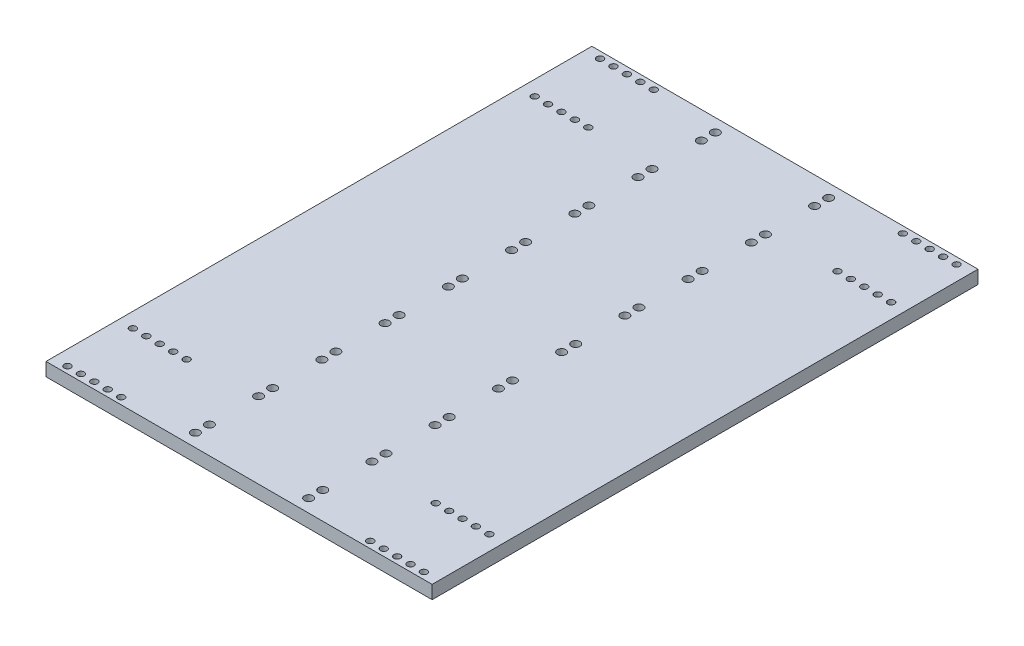
from build123d import *

# Parameters (mm, degrees)
SKETCH1_W           = 184.15
SKETCH1_H           = 260.35
BOSS_EXTRUDE1_DEPTH = 6.35
SKETCH2_R           = 2.032
CUT_EXTRUDE1_DEPTH  = 7.35
SKETCH3_R           = 1.6
CUT_EXTRUDE2_DEPTH  = 6.35


with BuildPart() as part:
    # Sketch1 → Boss-Extrude1 (new body)
    with BuildSketch(Plane(origin=(0, 0, 0), x_dir=(1, 0, 0), z_dir=(0, 1, 0))):
        Rectangle(SKETCH1_W, SKETCH1_H)
    extrude(amount=-BOSS_EXTRUDE1_DEPTH)

    # Sketch2 → Cut-Extrude1 (cut, through all)
    with BuildSketch(Plane(origin=(0, 0, 0), x_dir=(1, 0, 0), z_dir=(0, 1, 0))):
        with BuildLine():
            ThreePointArc((-24.98852, 117.2972), (-25.583679021, 118.734040979), (-27.02052, 119.3292))
            Line((-27.02052, 119.3292), (-27.02052, 117.2972))
            Line((-27.02052, 117.2972), (-24.98852, 117.2972))
        make_face()
        with BuildLine():
            Line((-27.02052, 117.2972), (-27.02052, 119.3292))
            ThreePointArc((-27.02052, 119.3292), (-28.457360979, 115.860359021), (-24.98852, 117.2972))
            Line((-24.98852, 117.2972), (-27.02052, 117.2972))
        make_face()
        with BuildLine():
            ThreePointArc((29.05252, 124.0028), (27.02052, 126.0348), (24.98852, 124.0028))
            Line((24.98852, 124.0028), (27.02052, 124.0028))
            Line((27.02052, 124.0028), (27.02052, 121.9708))
            ThreePointArc((27.02052, 121.9708), (28.457360979, 122.565959021), (29.05252, 124.0028))
        make_face()
        with BuildLine():
            Line((27.02052, 124.0028), (24.98852, 124.0028))
            ThreePointArc((24.98852, 124.0028), (25.583679021, 122.565959021), (27.02052, 121.9708))
            Line((27.02052, 121.9708), (27.02052, 124.0028))
        make_face()
        with BuildLine():
            ThreePointArc((27.02052, 119.3292), (25.583679021, 118.734040979), (24.98852, 117.2972))
            Line((24.98852, 117.2972), (27.02052, 117.2972))
            Line((27.02052, 117.2972), (27.02052, 119.3292))
        make_face()
        with BuildLine():
            Line((27.02052, 117.2972), (24.98852, 117.2972))
            ThreePointArc((24.98852, 117.2972), (27.02052, 115.2652), (29.05252, 117.2972))
            ThreePointArc((29.05252, 117.2972), (28.457360979, 118.734040979), (27.02052, 119.3292))
            Line((27.02052, 119.3292), (27.02052, 117.2972))
        make_face()
        with BuildLine():
            Line((-24.98852, 93.8403), (-27.02052, 93.8403))
            Line((-27.02052, 93.8403), (-27.02052, 91.8083))
            ThreePointArc((-27.02052, 91.8083), (-25.583679021, 92.403459021), (-24.98852, 93.8403))
        make_face()
        with BuildLine():
            Line((-27.02052, 91.8083), (-27.02052, 93.8403))
            Line((-27.02052, 93.8403), (-24.98852, 93.8403))
            ThreePointArc((-24.98852, 93.8403), (-28.457360979, 95.277140979), (-27.02052, 91.8083))
        make_face()
        with BuildLine():
            ThreePointArc((-24.98852, 87.1347), (-25.583679021, 88.571540979), (-27.02052, 89.1667))
            Line((-27.02052, 89.1667), (-27.02052, 87.1347))
            Line((-27.02052, 87.1347), (-24.98852, 87.1347))
        make_face()
        with BuildLine():
            Line((-27.02052, 87.1347), (-27.02052, 89.1667))
            ThreePointArc((-27.02052, 89.1667), (-28.457360979, 85.697859021), (-24.98852, 87.1347))
            Line((-24.98852, 87.1347), (-27.02052, 87.1347))
        make_face()
        with BuildLine():
            ThreePointArc((29.05252, 93.8403), (27.02052, 95.8723), (24.98852, 93.8403))
            Line((24.98852, 93.8403), (27.02052, 93.8403))
            Line((27.02052, 93.8403), (27.02052, 91.8083))
            ThreePointArc((27.02052, 91.8083), (28.457360979, 92.403459021), (29.05252, 93.8403))
        make_face()
        with BuildLine():
            Line((27.02052, 93.8403), (24.98852, 93.8403))
            ThreePointArc((24.98852, 93.8403), (25.583679021, 92.403459021), (27.02052, 91.8083))
            Line((27.02052, 91.8083), (27.02052, 93.8403))
        make_face()
        with BuildLine():
            ThreePointArc((27.02052, 89.1667), (25.583679021, 88.571540979), (24.98852, 87.1347))
            Line((24.98852, 87.1347), (27.02052, 87.1347))
            Line((27.02052, 87.1347), (27.02052, 89.1667))
        make_face()
        with BuildLine():
            Line((27.02052, 87.1347), (24.98852, 87.1347))
            ThreePointArc((24.98852, 87.1347), (27.02052, 85.1027), (29.05252, 87.1347))
            ThreePointArc((29.05252, 87.1347), (28.457360979, 88.571540979), (27.02052, 89.1667))
            Line((27.02052, 89.1667), (27.02052, 87.1347))
        make_face()
        with BuildLine():
            Line((-24.98852, 124.0028), (-27.02052, 124.0028))
            Line((-27.02052, 124.0028), (-27.02052, 121.9708))
            ThreePointArc((-27.02052, 121.9708), (-25.583679021, 122.565959021), (-24.98852, 124.0028))
        make_face()
        with BuildLine():
            Line((-27.02052, 121.9708), (-27.02052, 124.0028))
            Line((-27.02052, 124.0028), (-24.98852, 124.0028))
            ThreePointArc((-24.98852, 124.0028), (-28.457360979, 125.439640979), (-27.02052, 121.9708))
        make_face()
        with BuildLine():
            Line((-24.98852, 63.6778), (-27.02052, 63.6778))
            Line((-27.02052, 63.6778), (-27.02052, 61.6458))
            ThreePointArc((-27.02052, 61.6458), (-25.583679021, 62.240959021), (-24.98852, 63.6778))
        make_face()
        with BuildLine():
            Line((-27.02052, 61.6458), (-27.02052, 63.6778))
            Line((-27.02052, 63.6778), (-24.98852, 63.6778))
            ThreePointArc((-24.98852, 63.6778), (-28.457360979, 65.114640979), (-27.02052, 61.6458))
        make_face()
        with BuildLine():
            ThreePointArc((-24.98852, 56.9722), (-25.583679021, 58.409040979), (-27.02052, 59.0042))
            Line((-27.02052, 59.0042), (-27.02052, 56.9722))
            Line((-27.02052, 56.9722), (-24.98852, 56.9722))
        make_face()
        with BuildLine():
            Line((-27.02052, 56.9722), (-27.02052, 59.0042))
            ThreePointArc((-27.02052, 59.0042), (-28.457360979, 55.535359021), (-24.98852, 56.9722))
            Line((-24.98852, 56.9722), (-27.02052, 56.9722))
        make_face()
        with BuildLine():
            ThreePointArc((29.05252, 63.6778), (27.02052, 65.7098), (24.98852, 63.6778))
            Line((24.98852, 63.6778), (27.02052, 63.6778))
            Line((27.02052, 63.6778), (27.02052, 61.6458))
            ThreePointArc((27.02052, 61.6458), (28.457360979, 62.240959021), (29.05252, 63.6778))
        make_face()
        with BuildLine():
            Line((27.02052, 63.6778), (24.98852, 63.6778))
            ThreePointArc((24.98852, 63.6778), (25.583679021, 62.240959021), (27.02052, 61.6458))
            Line((27.02052, 61.6458), (27.02052, 63.6778))
        make_face()
        with BuildLine():
            ThreePointArc((27.02052, 59.0042), (25.583679021, 58.409040979), (24.98852, 56.9722))
            Line((24.98852, 56.9722), (27.02052, 56.9722))
            Line((27.02052, 56.9722), (27.02052, 59.0042))
        make_face()
        with BuildLine():
            Line((27.02052, 56.9722), (24.98852, 56.9722))
            ThreePointArc((24.98852, 56.9722), (27.02052, 54.9402), (29.05252, 56.9722))
            ThreePointArc((29.05252, 56.9722), (28.457360979, 58.409040979), (27.02052, 59.0042))
            Line((27.02052, 59.0042), (27.02052, 56.9722))
        make_face()
        with BuildLine():
            Line((-24.98852, 33.5153), (-27.02052, 33.5153))
            Line((-27.02052, 33.5153), (-27.02052, 31.4833))
            ThreePointArc((-27.02052, 31.4833), (-25.583679021, 32.078459021), (-24.98852, 33.5153))
        make_face()
        with BuildLine():
            Line((-27.02052, 31.4833), (-27.02052, 33.5153))
            Line((-27.02052, 33.5153), (-24.98852, 33.5153))
            ThreePointArc((-24.98852, 33.5153), (-28.457360979, 34.952140979), (-27.02052, 31.4833))
        make_face()
        with BuildLine():
            ThreePointArc((-24.98852, 26.8097), (-25.583679021, 28.246540979), (-27.02052, 28.8417))
            Line((-27.02052, 28.8417), (-27.02052, 26.8097))
            Line((-27.02052, 26.8097), (-24.98852, 26.8097))
        make_face()
        with BuildLine():
            Line((-27.02052, 26.8097), (-27.02052, 28.8417))
            ThreePointArc((-27.02052, 28.8417), (-28.457360979, 25.372859021), (-24.98852, 26.8097))
            Line((-24.98852, 26.8097), (-27.02052, 26.8097))
        make_face()
        with BuildLine():
            ThreePointArc((29.05252, 33.5153), (27.02052, 35.5473), (24.98852, 33.5153))
            Line((24.98852, 33.5153), (27.02052, 33.5153))
            Line((27.02052, 33.5153), (27.02052, 31.4833))
            ThreePointArc((27.02052, 31.4833), (28.457360979, 32.078459021), (29.05252, 33.5153))
        make_face()
        with BuildLine():
            Line((27.02052, 33.5153), (24.98852, 33.5153))
            ThreePointArc((24.98852, 33.5153), (25.583679021, 32.078459021), (27.02052, 31.4833))
            Line((27.02052, 31.4833), (27.02052, 33.5153))
        make_face()
        with BuildLine():
            ThreePointArc((27.02052, 28.8417), (25.583679021, 28.246540979), (24.98852, 26.8097))
            Line((24.98852, 26.8097), (27.02052, 26.8097))
            Line((27.02052, 26.8097), (27.02052, 28.8417))
        make_face()
        with BuildLine():
            Line((27.02052, 26.8097), (24.98852, 26.8097))
            ThreePointArc((24.98852, 26.8097), (27.02052, 24.7777), (29.05252, 26.8097))
            ThreePointArc((29.05252, 26.8097), (28.457360979, 28.246540979), (27.02052, 28.8417))
            Line((27.02052, 28.8417), (27.02052, 26.8097))
        make_face()
        with BuildLine():
            Line((-24.98852, 3.3528), (-27.02052, 3.3528))
            Line((-27.02052, 3.3528), (-27.02052, 1.3208))
            ThreePointArc((-27.02052, 1.3208), (-25.583679021, 1.915959021), (-24.98852, 3.3528))
        make_face()
        with BuildLine():
            Line((-27.02052, 1.3208), (-27.02052, 3.3528))
            Line((-27.02052, 3.3528), (-24.98852, 3.3528))
            ThreePointArc((-24.98852, 3.3528), (-28.457360979, 4.789640979), (-27.02052, 1.3208))
        make_face()
        with BuildLine():
            ThreePointArc((-24.98852, -3.3528), (-25.583679021, -1.915959021), (-27.02052, -1.3208))
            Line((-27.02052, -1.3208), (-27.02052, -3.3528))
            Line((-27.02052, -3.3528), (-24.98852, -3.3528))
        make_face()
        with BuildLine():
            Line((-27.02052, -3.3528), (-27.02052, -1.3208))
            ThreePointArc((-27.02052, -1.3208), (-28.457360979, -4.789640979), (-24.98852, -3.3528))
            Line((-24.98852, -3.3528), (-27.02052, -3.3528))
        make_face()
        with BuildLine():
            ThreePointArc((29.05252, 3.3528), (27.02052, 5.3848), (24.98852, 3.3528))
            Line((24.98852, 3.3528), (27.02052, 3.3528))
            Line((27.02052, 3.3528), (27.02052, 1.3208))
            ThreePointArc((27.02052, 1.3208), (28.457360979, 1.915959021), (29.05252, 3.3528))
        make_face()
        with BuildLine():
            Line((27.02052, 3.3528), (24.98852, 3.3528))
            ThreePointArc((24.98852, 3.3528), (25.583679021, 1.915959021), (27.02052, 1.3208))
            Line((27.02052, 1.3208), (27.02052, 3.3528))
        make_face()
        with BuildLine():
            ThreePointArc((27.02052, -1.3208), (25.583679021, -1.915959021), (24.98852, -3.3528))
            Line((24.98852, -3.3528), (27.02052, -3.3528))
            Line((27.02052, -3.3528), (27.02052, -1.3208))
        make_face()
        with BuildLine():
            Line((27.02052, -3.3528), (24.98852, -3.3528))
            ThreePointArc((24.98852, -3.3528), (27.02052, -5.3848), (29.05252, -3.3528))
            ThreePointArc((29.05252, -3.3528), (28.457360979, -1.915959021), (27.02052, -1.3208))
            Line((27.02052, -1.3208), (27.02052, -3.3528))
        make_face()
        with BuildLine():
            Line((-24.98852, -26.8097), (-27.02052, -26.8097))
            Line((-27.02052, -26.8097), (-27.02052, -28.8417))
            ThreePointArc((-27.02052, -28.8417), (-25.583679021, -28.246540979), (-24.98852, -26.8097))
        make_face()
        with BuildLine():
            Line((-27.02052, -28.8417), (-27.02052, -26.8097))
            Line((-27.02052, -26.8097), (-24.98852, -26.8097))
            ThreePointArc((-24.98852, -26.8097), (-28.457360979, -25.372859021), (-27.02052, -28.8417))
        make_face()
        with Locations((-27.02052, -33.5153)):
            Circle(SKETCH2_R)
        with Locations((27.02052, -26.8097)):
            Circle(SKETCH2_R)
        with Locations((27.02052, -33.5153)):
            Circle(SKETCH2_R)
        with Locations((-27.02052, -56.9722)):
            Circle(SKETCH2_R)
        with Locations((-27.02052, -63.6778)):
            Circle(SKETCH2_R)
        with Locations((27.02052, -56.9722)):
            Circle(SKETCH2_R)
        with Locations((27.02052, -63.6778)):
            Circle(SKETCH2_R)
        with Locations((-27.02052, -87.1347)):
            Circle(SKETCH2_R)
        with Locations((-27.02052, -93.8403)):
            Circle(SKETCH2_R)
        with Locations((27.02052, -87.1347)):
            Circle(SKETCH2_R)
        with Locations((27.02052, -93.8403)):
            Circle(SKETCH2_R)
        with Locations((27.02052, -117.2972)):
            Circle(SKETCH2_R)
        with Locations((-27.02052, -117.2972)):
            Circle(SKETCH2_R)
        with Locations((-27.02052, -124.0028)):
            Circle(SKETCH2_R)
        with Locations((27.02052, -124.0028)):
            Circle(SKETCH2_R)
    extrude(amount=-CUT_EXTRUDE1_DEPTH, mode=Mode.SUBTRACT)

    # Sketch3 → Cut-Extrude2 (cut)
    with BuildSketch(Plane(origin=(0, 0, 0), x_dir=(1, 0, 0), z_dir=(0, 1, 0))):
        with Locations((-59.40552, -95.8)):
            Circle(SKETCH3_R)
        with Locations((-65.80552, -95.8)):
            Circle(SKETCH3_R)
        with Locations((-72.20552, -95.8)):
            Circle(SKETCH3_R)
        with Locations((-78.60552, -95.8)):
            Circle(SKETCH3_R)
        with Locations((-85.00552, -95.8)):
            Circle(SKETCH3_R)
        with Locations((-59.40552, -127)):
            Circle(SKETCH3_R)
        with Locations((-65.80552, -127)):
            Circle(SKETCH3_R)
        with Locations((-72.20552, -127)):
            Circle(SKETCH3_R)
        with Locations((-78.60552, -127)):
            Circle(SKETCH3_R)
        with Locations((-85.00552, -127)):
            Circle(SKETCH3_R)
        with Locations((59.40552, -127)):
            Circle(SKETCH3_R)
        with Locations((59.40552, -95.8)):
            Circle(SKETCH3_R)
        with Locations((65.80552, -95.8)):
            Circle(SKETCH3_R)
        with Locations((72.20552, -95.8)):
            Circle(SKETCH3_R)
        with Locations((78.60552, -95.8)):
            Circle(SKETCH3_R)
        with Locations((85.00552, -95.8)):
            Circle(SKETCH3_R)
        with Locations((65.80552, -127)):
            Circle(SKETCH3_R)
        with Locations((72.20552, -127)):
            Circle(SKETCH3_R)
        with Locations((78.60552, -127)):
            Circle(SKETCH3_R)
        with Locations((85.00552, -127)):
            Circle(SKETCH3_R)
        with Locations((85.00552, 95.8)):
            Circle(SKETCH3_R)
        with Locations((78.60552, 95.8)):
            Circle(SKETCH3_R)
        with Locations((72.20552, 95.8)):
            Circle(SKETCH3_R)
        with Locations((65.80552, 95.8)):
            Circle(SKETCH3_R)
        with Locations((59.40552, 127)):
            Circle(SKETCH3_R)
        with Locations((65.80552, 127)):
            Circle(SKETCH3_R)
        with Locations((72.20552, 127)):
            Circle(SKETCH3_R)
        with Locations((78.60552, 127)):
            Circle(SKETCH3_R)
        with Locations((85.00552, 127)):
            Circle(SKETCH3_R)
        with Locations((59.40552, 95.8)):
            Circle(SKETCH3_R)
        with Locations((-59.40552, 95.8)):
            Circle(SKETCH3_R)
        with Locations((-65.80552, 95.8)):
            Circle(SKETCH3_R)
        with Locations((-72.20552, 95.8)):
            Circle(SKETCH3_R)
        with Locations((-78.60552, 95.8)):
            Circle(SKETCH3_R)
        with Locations((-85.00552, 95.8)):
            Circle(SKETCH3_R)
        with Locations((-59.40552, 127)):
            Circle(SKETCH3_R)
        with Locations((-65.80552, 127)):
            Circle(SKETCH3_R)
        with Locations((-72.20552, 127)):
            Circle(SKETCH3_R)
        with Locations((-78.60552, 127)):
            Circle(SKETCH3_R)
        with Locations((-85.00552, 127)):
            Circle(SKETCH3_R)
    extrude(amount=-CUT_EXTRUDE2_DEPTH, mode=Mode.SUBTRACT)


solid = part.part
